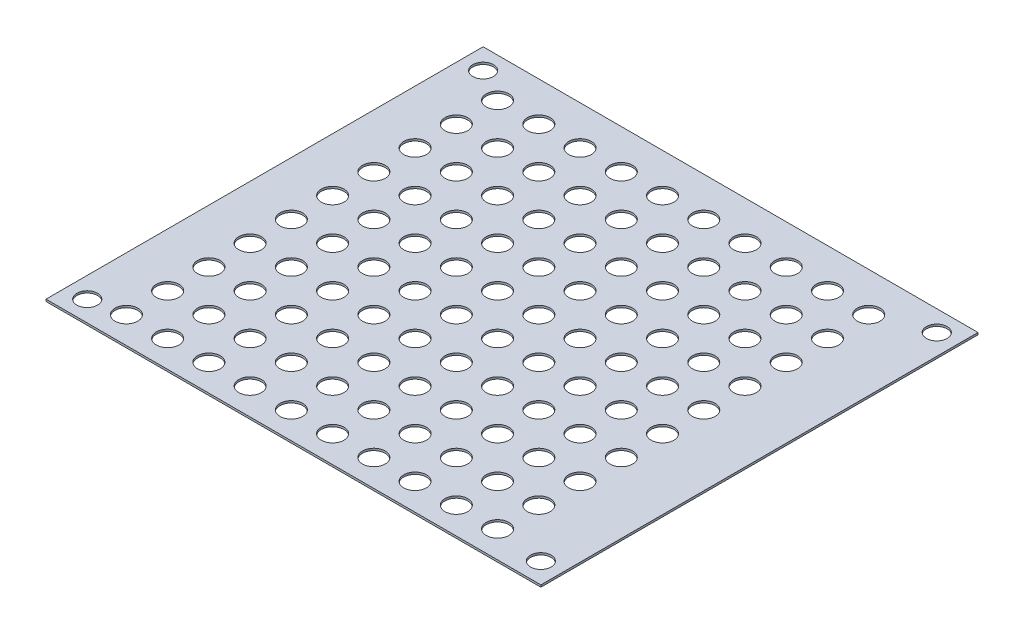
from build123d import *

# Parameters (mm, degrees)
SKETCH1_W           = 120
SKETCH1_H           = 106
SKETCH1_R           = 2.75
SKETCH1_R_2         = 2.5
BOSS_EXTRUDE1_DEPTH = 0.5


with BuildPart() as part:
    # Sketch1 → Boss-Extrude1 (new body)
    with BuildSketch(Plane(origin=(0, 0, 0), x_dir=(1, 0, 0), z_dir=(0, 1, 0))):
        with Locations((60, 53)):
            Rectangle(SKETCH1_W, SKETCH1_H)
        with Locations((13, 36.5)):
            Circle(SKETCH1_R, mode=Mode.SUBTRACT)
        with Locations((23, 36.5)):
            Circle(SKETCH1_R, mode=Mode.SUBTRACT)
        with Locations((13, 6.5)):
            Circle(SKETCH1_R, mode=Mode.SUBTRACT)
        with Locations((5, 5)):
            Circle(SKETCH1_R_2, mode=Mode.SUBTRACT)
        with Locations((5, 101)):
            Circle(SKETCH1_R_2, mode=Mode.SUBTRACT)
        with Locations((115, 101)):
            Circle(SKETCH1_R_2, mode=Mode.SUBTRACT)
        with Locations((115, 5)):
            Circle(SKETCH1_R_2, mode=Mode.SUBTRACT)
        with Locations((23, 6.5)):
            Circle(SKETCH1_R, mode=Mode.SUBTRACT)
        with Locations((33, 6.5)):
            Circle(SKETCH1_R, mode=Mode.SUBTRACT)
        with Locations((23, 16.5)):
            Circle(SKETCH1_R, mode=Mode.SUBTRACT)
        with Locations((33, 16.5)):
            Circle(SKETCH1_R, mode=Mode.SUBTRACT)
        with Locations((23, 26.5)):
            Circle(SKETCH1_R, mode=Mode.SUBTRACT)
        with Locations((33, 26.5)):
            Circle(SKETCH1_R, mode=Mode.SUBTRACT)
        with Locations((13, 16.5)):
            Circle(SKETCH1_R, mode=Mode.SUBTRACT)
        with Locations((13, 26.5)):
            Circle(SKETCH1_R, mode=Mode.SUBTRACT)
        with Locations((33, 36.5)):
            Circle(SKETCH1_R, mode=Mode.SUBTRACT)
        with Locations((13, 46.5)):
            Circle(SKETCH1_R, mode=Mode.SUBTRACT)
        with Locations((23, 46.5)):
            Circle(SKETCH1_R, mode=Mode.SUBTRACT)
        with Locations((33, 46.5)):
            Circle(SKETCH1_R, mode=Mode.SUBTRACT)
        with Locations((13, 56.5)):
            Circle(SKETCH1_R, mode=Mode.SUBTRACT)
        with Locations((23, 56.5)):
            Circle(SKETCH1_R, mode=Mode.SUBTRACT)
        with Locations((33, 56.5)):
            Circle(SKETCH1_R, mode=Mode.SUBTRACT)
        with Locations((13, 66.5)):
            Circle(SKETCH1_R, mode=Mode.SUBTRACT)
        with Locations((23, 66.5)):
            Circle(SKETCH1_R, mode=Mode.SUBTRACT)
        with Locations((33, 66.5)):
            Circle(SKETCH1_R, mode=Mode.SUBTRACT)
        with Locations((13, 76.5)):
            Circle(SKETCH1_R, mode=Mode.SUBTRACT)
        with Locations((23, 76.5)):
            Circle(SKETCH1_R, mode=Mode.SUBTRACT)
        with Locations((33, 76.5)):
            Circle(SKETCH1_R, mode=Mode.SUBTRACT)
        with Locations((13, 86.5)):
            Circle(SKETCH1_R, mode=Mode.SUBTRACT)
        with Locations((23, 86.5)):
            Circle(SKETCH1_R, mode=Mode.SUBTRACT)
        with Locations((33, 86.5)):
            Circle(SKETCH1_R, mode=Mode.SUBTRACT)
        with Locations((13, 96.5)):
            Circle(SKETCH1_R, mode=Mode.SUBTRACT)
        with Locations((23, 96.5)):
            Circle(SKETCH1_R, mode=Mode.SUBTRACT)
        with Locations((33, 96.5)):
            Circle(SKETCH1_R, mode=Mode.SUBTRACT)
        with Locations((43, 6.5)):
            Circle(SKETCH1_R, mode=Mode.SUBTRACT)
        with Locations((53, 6.5)):
            Circle(SKETCH1_R, mode=Mode.SUBTRACT)
        with Locations((63, 6.5)):
            Circle(SKETCH1_R, mode=Mode.SUBTRACT)
        with Locations((73, 6.5)):
            Circle(SKETCH1_R, mode=Mode.SUBTRACT)
        with Locations((83, 6.5)):
            Circle(SKETCH1_R, mode=Mode.SUBTRACT)
        with Locations((93, 6.5)):
            Circle(SKETCH1_R, mode=Mode.SUBTRACT)
        with Locations((103, 6.5)):
            Circle(SKETCH1_R, mode=Mode.SUBTRACT)
        with Locations((43, 16.5)):
            Circle(SKETCH1_R, mode=Mode.SUBTRACT)
        with Locations((53, 16.5)):
            Circle(SKETCH1_R, mode=Mode.SUBTRACT)
        with Locations((63, 16.5)):
            Circle(SKETCH1_R, mode=Mode.SUBTRACT)
        with Locations((73, 16.5)):
            Circle(SKETCH1_R, mode=Mode.SUBTRACT)
        with Locations((83, 16.5)):
            Circle(SKETCH1_R, mode=Mode.SUBTRACT)
        with Locations((93, 16.5)):
            Circle(SKETCH1_R, mode=Mode.SUBTRACT)
        with Locations((103, 16.5)):
            Circle(SKETCH1_R, mode=Mode.SUBTRACT)
        with Locations((43, 26.5)):
            Circle(SKETCH1_R, mode=Mode.SUBTRACT)
        with Locations((53, 26.5)):
            Circle(SKETCH1_R, mode=Mode.SUBTRACT)
        with Locations((63, 26.5)):
            Circle(SKETCH1_R, mode=Mode.SUBTRACT)
        with Locations((73, 26.5)):
            Circle(SKETCH1_R, mode=Mode.SUBTRACT)
        with Locations((83, 26.5)):
            Circle(SKETCH1_R, mode=Mode.SUBTRACT)
        with Locations((93, 26.5)):
            Circle(SKETCH1_R, mode=Mode.SUBTRACT)
        with Locations((103, 26.5)):
            Circle(SKETCH1_R, mode=Mode.SUBTRACT)
        with Locations((43, 36.5)):
            Circle(SKETCH1_R, mode=Mode.SUBTRACT)
        with Locations((53, 36.5)):
            Circle(SKETCH1_R, mode=Mode.SUBTRACT)
        with Locations((63, 36.5)):
            Circle(SKETCH1_R, mode=Mode.SUBTRACT)
        with Locations((73, 36.5)):
            Circle(SKETCH1_R, mode=Mode.SUBTRACT)
        with Locations((83, 36.5)):
            Circle(SKETCH1_R, mode=Mode.SUBTRACT)
        with Locations((93, 36.5)):
            Circle(SKETCH1_R, mode=Mode.SUBTRACT)
        with Locations((103, 36.5)):
            Circle(SKETCH1_R, mode=Mode.SUBTRACT)
        with Locations((43, 46.5)):
            Circle(SKETCH1_R, mode=Mode.SUBTRACT)
        with Locations((53, 46.5)):
            Circle(SKETCH1_R, mode=Mode.SUBTRACT)
        with Locations((63, 46.5)):
            Circle(SKETCH1_R, mode=Mode.SUBTRACT)
        with Locations((73, 46.5)):
            Circle(SKETCH1_R, mode=Mode.SUBTRACT)
        with Locations((83, 46.5)):
            Circle(SKETCH1_R, mode=Mode.SUBTRACT)
        with Locations((93, 46.5)):
            Circle(SKETCH1_R, mode=Mode.SUBTRACT)
        with Locations((103, 46.5)):
            Circle(SKETCH1_R, mode=Mode.SUBTRACT)
        with Locations((43, 56.5)):
            Circle(SKETCH1_R, mode=Mode.SUBTRACT)
        with Locations((53, 56.5)):
            Circle(SKETCH1_R, mode=Mode.SUBTRACT)
        with Locations((63, 56.5)):
            Circle(SKETCH1_R, mode=Mode.SUBTRACT)
        with Locations((73, 56.5)):
            Circle(SKETCH1_R, mode=Mode.SUBTRACT)
        with Locations((83, 56.5)):
            Circle(SKETCH1_R, mode=Mode.SUBTRACT)
        with Locations((93, 56.5)):
            Circle(SKETCH1_R, mode=Mode.SUBTRACT)
        with Locations((103, 56.5)):
            Circle(SKETCH1_R, mode=Mode.SUBTRACT)
        with Locations((43, 66.5)):
            Circle(SKETCH1_R, mode=Mode.SUBTRACT)
        with Locations((53, 66.5)):
            Circle(SKETCH1_R, mode=Mode.SUBTRACT)
        with Locations((63, 66.5)):
            Circle(SKETCH1_R, mode=Mode.SUBTRACT)
        with Locations((73, 66.5)):
            Circle(SKETCH1_R, mode=Mode.SUBTRACT)
        with Locations((83, 66.5)):
            Circle(SKETCH1_R, mode=Mode.SUBTRACT)
        with Locations((93, 66.5)):
            Circle(SKETCH1_R, mode=Mode.SUBTRACT)
        with Locations((103, 66.5)):
            Circle(SKETCH1_R, mode=Mode.SUBTRACT)
        with Locations((43, 76.5)):
            Circle(SKETCH1_R, mode=Mode.SUBTRACT)
        with Locations((53, 76.5)):
            Circle(SKETCH1_R, mode=Mode.SUBTRACT)
        with Locations((63, 76.5)):
            Circle(SKETCH1_R, mode=Mode.SUBTRACT)
        with Locations((73, 76.5)):
            Circle(SKETCH1_R, mode=Mode.SUBTRACT)
        with Locations((83, 76.5)):
            Circle(SKETCH1_R, mode=Mode.SUBTRACT)
        with Locations((93, 76.5)):
            Circle(SKETCH1_R, mode=Mode.SUBTRACT)
        with Locations((103, 76.5)):
            Circle(SKETCH1_R, mode=Mode.SUBTRACT)
        with Locations((43, 86.5)):
            Circle(SKETCH1_R, mode=Mode.SUBTRACT)
        with Locations((53, 86.5)):
            Circle(SKETCH1_R, mode=Mode.SUBTRACT)
        with Locations((63, 86.5)):
            Circle(SKETCH1_R, mode=Mode.SUBTRACT)
        with Locations((73, 86.5)):
            Circle(SKETCH1_R, mode=Mode.SUBTRACT)
        with Locations((83, 86.5)):
            Circle(SKETCH1_R, mode=Mode.SUBTRACT)
        with Locations((93, 86.5)):
            Circle(SKETCH1_R, mode=Mode.SUBTRACT)
        with Locations((103, 86.5)):
            Circle(SKETCH1_R, mode=Mode.SUBTRACT)
        with Locations((43, 96.5)):
            Circle(SKETCH1_R, mode=Mode.SUBTRACT)
        with Locations((53, 96.5)):
            Circle(SKETCH1_R, mode=Mode.SUBTRACT)
        with Locations((63, 96.5)):
            Circle(SKETCH1_R, mode=Mode.SUBTRACT)
        with Locations((73, 96.5)):
            Circle(SKETCH1_R, mode=Mode.SUBTRACT)
        with Locations((83, 96.5)):
            Circle(SKETCH1_R, mode=Mode.SUBTRACT)
        with Locations((93, 96.5)):
            Circle(SKETCH1_R, mode=Mode.SUBTRACT)
        with Locations((103, 96.5)):
            Circle(SKETCH1_R, mode=Mode.SUBTRACT)
    extrude(amount=BOSS_EXTRUDE1_DEPTH)


solid = part.part
